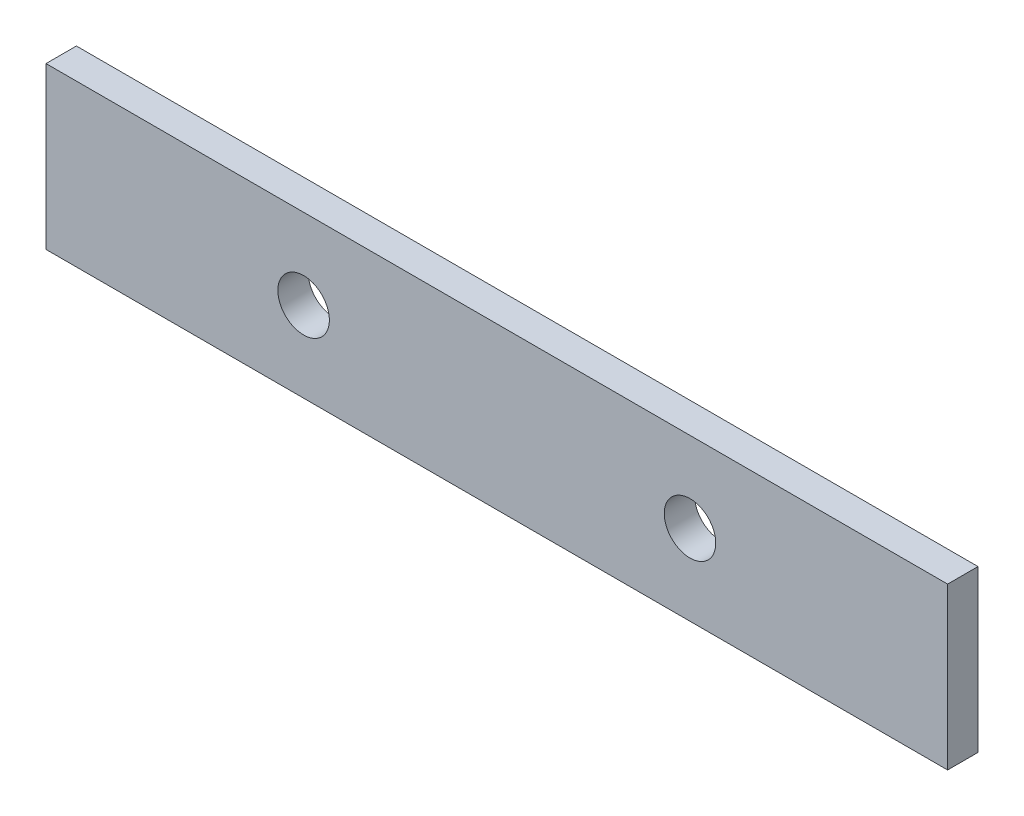
from build123d import *

# Parameters (mm, degrees)
SKETCH1_W           = 88.9
SKETCH1_H           = 15.875
BOSS_EXTRUDE1_DEPTH = 1.4986
SKETCH2_R           = 2.54
CUT_EXTRUDE1_DEPTH  = 3.9972


with BuildPart() as part:
    # Sketch1 → Boss-Extrude1 (new body, symmetric)
    with BuildSketch(Plane.XY):
        Rectangle(SKETCH1_W, SKETCH1_H)
    extrude(amount=BOSS_EXTRUDE1_DEPTH, both=True)

    # Sketch2 → Cut-Extrude1 (cut, through all)
    with BuildSketch(Plane(origin=(0, 0, -1.4986), x_dir=(-1, 0, 0), z_dir=(0, 0, -1))):
        with Locations((-19.05, 0)):
            Circle(SKETCH2_R)
        with Locations((19.05, 0)):
            Circle(SKETCH2_R)
    extrude(amount=-CUT_EXTRUDE1_DEPTH, mode=Mode.SUBTRACT)


solid = part.part
